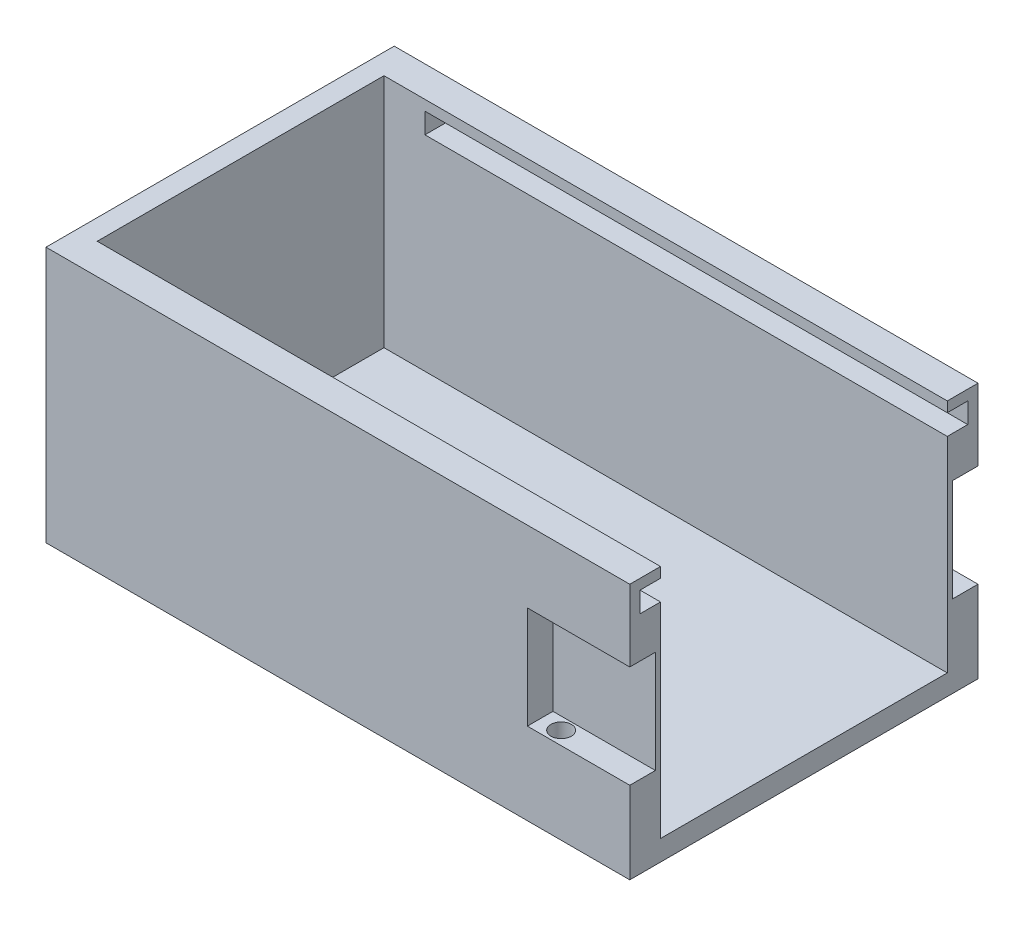
from build123d import *

# Parameters (mm, degrees)
SKETCH1_W                = 59
SKETCH1_H                = 34
SKETCH1_W_2              = 55
SKETCH1_H_2              = 28
BOSS_EXTRUDE1_DEPTH      = 25
SKETCH1_2_W              = 55
SKETCH1_2_H              = 28
BOSS_EXTRUDE2_DEPTH      = 2
SKETCH2_W                = 2
SKETCH2_H                = 34
CUT_EXTRUDE1_DEPTH       = 25
SKETCH5_W                = 2
SKETCH5_H                = 2
CUT_EXTRUDE4_DEPTH       = 51
SKETCH9_W                = 10
SKETCH9_H                = 10
CUT_EXTRUDE7_DEPTH       = 2.5
SKETCH10_W               = 10
SKETCH10_H               = 10
CUT_EXTRUDE8_DEPTH       = 2.5
CUT_EXTRUDE9_DEPTH       = 12.5
CUT_EXTRUDE9_DEPTH_BACK  = 2.5
SKETCH11_R               = 1
CUT_EXTRUDE10_DEPTH      = 12.5
CUT_EXTRUDE10_DEPTH_BACK = 2.5
SKETCH12_R               = 1


with BuildPart() as part:
    # Sketch1 → Boss-Extrude1 (new body)
    with BuildSketch(Plane(origin=(0, 0, 0), x_dir=(1, 0, 0), z_dir=(0, 1, 0))):
        with Locations((29.5, 17)):
            Rectangle(SKETCH1_W, SKETCH1_H)
        with Locations((29.5, 17)):
            Rectangle(SKETCH1_W_2, SKETCH1_H_2, mode=Mode.SUBTRACT)
    extrude(amount=BOSS_EXTRUDE1_DEPTH)

    # Sketch1_2 → Boss-Extrude2 (add)
    with BuildSketch(Plane(origin=(0, 0, 0), x_dir=(1, 0, 0), z_dir=(0, 1, 0))):
        with Locations((29.5, 17)):
            Rectangle(SKETCH1_2_W, SKETCH1_2_H)
    extrude(amount=BOSS_EXTRUDE2_DEPTH)

    # Sketch2 → Cut-Extrude1 (cut)
    with BuildSketch(Plane(origin=(0, 25, 0), x_dir=(1, 0, 0), z_dir=(0, 1, 0))):
        with Locations((58, 17)):
            Rectangle(SKETCH2_W, SKETCH2_H)
    extrude(amount=-CUT_EXTRUDE1_DEPTH, mode=Mode.SUBTRACT)

    # Sketch5 → Cut-Extrude4 (cut)
    with BuildSketch(Plane(origin=(57, 0, 0), x_dir=(0, 0, -1), z_dir=(1, 0, 0))):
        with Locations((2, 23)):
            Rectangle(SKETCH5_W, SKETCH5_H)
        with Locations((32, 23)):
            Rectangle(SKETCH5_W, SKETCH5_H)
    extrude(amount=-CUT_EXTRUDE4_DEPTH, mode=Mode.SUBTRACT)

    # Sketch9 → Cut-Extrude7 (cut)
    with BuildSketch(Plane(origin=(0, 0, -34), x_dir=(-1, 0, 0), z_dir=(0, 0, -1))):
        with Locations((-52, 13)):
            Rectangle(SKETCH9_W, SKETCH9_H)
    extrude(amount=-CUT_EXTRUDE7_DEPTH, mode=Mode.SUBTRACT)

    # Sketch10 → Cut-Extrude8 (cut)
    with BuildSketch(Plane.XY):
        with Locations((52, 13)):
            Rectangle(SKETCH10_W, SKETCH10_H)
    extrude(amount=-CUT_EXTRUDE8_DEPTH, mode=Mode.SUBTRACT)

    # Sketch11 → Cut-Extrude9 (cut, two sides: drawn at the far end of the back side and taken through both)
    with BuildSketch(Plane(origin=(0, 18, 0), x_dir=(-1, 0, 0), z_dir=(0, -1, 0)).offset(-CUT_EXTRUDE9_DEPTH_BACK)):
        with Locations((-49, 1.3)):
            Circle(SKETCH11_R)
    extrude(amount=CUT_EXTRUDE9_DEPTH + CUT_EXTRUDE9_DEPTH_BACK, mode=Mode.SUBTRACT)

    # Sketch12 → Cut-Extrude10 (cut, two sides: drawn at the far end of the back side and taken through both)
    with BuildSketch(Plane(origin=(0, 18, 0), x_dir=(-1, 0, 0), z_dir=(0, -1, 0)).offset(-CUT_EXTRUDE10_DEPTH_BACK)):
        with Locations((-48.8, 32.7)):
            Circle(SKETCH12_R)
    extrude(amount=CUT_EXTRUDE10_DEPTH + CUT_EXTRUDE10_DEPTH_BACK, mode=Mode.SUBTRACT)


solid = part.part
